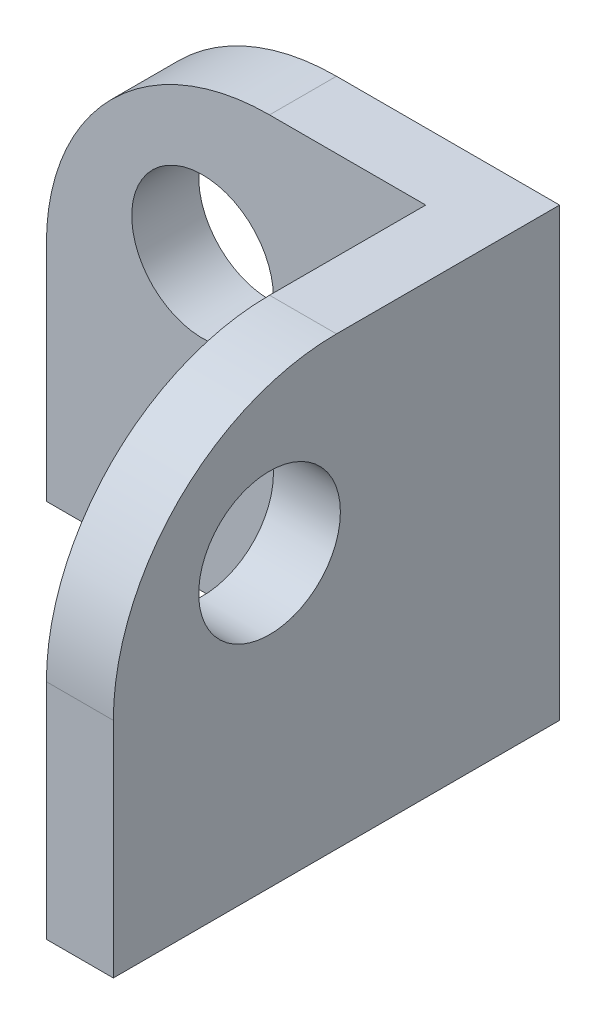
from build123d import *

# Parameters (mm, degrees)
BOSS_EXTRUDE1_DEPTH = 20
FILLET1_R           = 10
SKETCH2_R           = 3.175
CUT_EXTRUDE1_DEPTH  = 21
SKETCH3_R           = 3.175
CUT_EXTRUDE2_DEPTH  = 4


with BuildPart() as part:
    # Sketch1 → Boss-Extrude1 (new body)
    with BuildSketch(Plane(origin=(0, 0, 0), x_dir=(1, 0, 0), z_dir=(0, 1, 0))):
        Polygon((-18.5, -1.5), (-1.5, -1.5), (-1.5, -18.5), (1.5, -18.5), (1.5, 1.5), (-18.5, 1.5), align=None)
    extrude(amount=BOSS_EXTRUDE1_DEPTH)

    # Fillet1
    fillet1_edges = [part.edges().sort_by_distance(p)[0] for p in [
        (0, 20, 18.5),
        (-18.5, 20, 0),
    ]]
    fillet(fillet1_edges, radius=FILLET1_R)

    # Sketch2 → Cut-Extrude1 (cut, through all)
    with BuildSketch(Plane(origin=(1.5, 0, 0), x_dir=(0, 0, -1), z_dir=(1, 0, 0))):
        with Locations((-11.5, 13)):
            Circle(SKETCH2_R)
    extrude(amount=-CUT_EXTRUDE1_DEPTH, mode=Mode.SUBTRACT)

    # Sketch3 → Cut-Extrude2 (cut, through all)
    with BuildSketch(Plane.XY.offset(1.5)):
        with Locations((-11.5, 13)):
            Circle(SKETCH3_R)
    extrude(amount=-CUT_EXTRUDE2_DEPTH, mode=Mode.SUBTRACT)


solid = part.part
